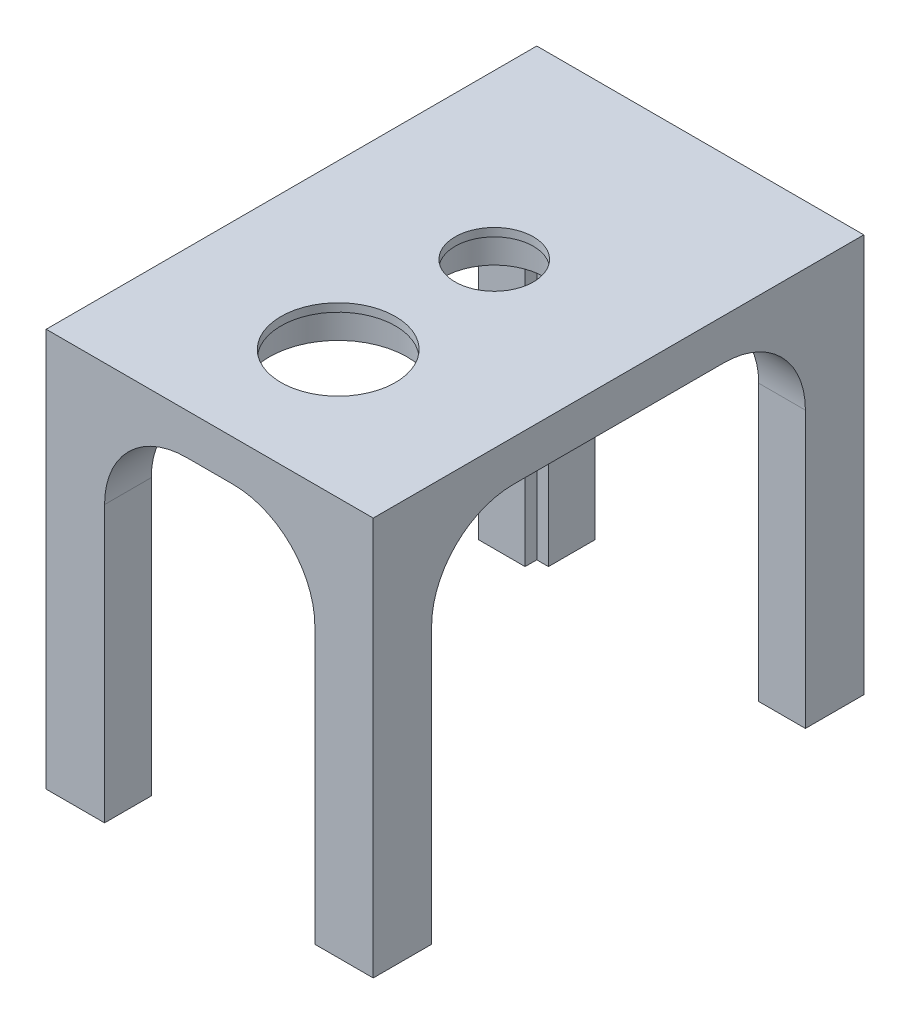
from build123d import *

# Parameters (mm, degrees)
SKETCH1_W               = 71.12
SKETCH1_H               = 106.68
BOSS_EXTRUDE1_DEPTH     = 87.884
SHELL1_T                = -10.16
SKETCH3_R               = 1.5875
CUT_EXTRUDE1_DEPTH      = 10.16
SKETCH4_W               = 81.28
SKETCH4_H               = 77.724
CUT_EXTRUDE2_DEPTH      = 72.12
CUT_EXTRUDE3_DEPTH      = 3.175
SKETCH7_W               = 45.72
SKETCH7_H               = 77.724
CUT_EXTRUDE4_DEPTH      = 1
CUT_EXTRUDE4_DEPTH_BACK = 107.68
SKETCH9_W               = 71.12
SKETCH9_H               = 106.68
CUT_EXTRUDE6_DEPTH      = 1.27
SKETCH10_R              = 14.986
SKETCH10_R_2            = 11.049
CUT_EXTRUDE7_DEPTH      = 7.112
SKETCH11_R              = 12.446
SKETCH11_R_2            = 8.509
CUT_EXTRUDE9_DEPTH      = 9.89
FILLET1_R               = 17.78


with BuildPart() as part:
    # Sketch1 → Boss-Extrude1 (new body)
    with BuildSketch(Plane(origin=(0, 0, 0), x_dir=(1, 0, 0), z_dir=(0, 1, 0))):
        with Locations((35.56, 53.34)):
            Rectangle(SKETCH1_W, SKETCH1_H)
    extrude(amount=BOSS_EXTRUDE1_DEPTH)

    # Shell1
    shell1_openings = [part.faces().sort_by_distance(p)[0] for p in [
        (35.56, 0, -53.34),
    ]]
    offset(amount=SHELL1_T, openings=shell1_openings, kind=Kind.INTERSECTION)

    # Sketch3 → Cut-Extrude1 (cut)
    with BuildSketch(Plane.XZ):
        with Locations((6.35, -6.35)):
            Circle(SKETCH3_R)
        with Locations((64.77, -6.35)):
            Circle(SKETCH3_R)
        with Locations((64.77, -100.33)):
            Circle(SKETCH3_R)
        with Locations((6.35, -100.33)):
            Circle(SKETCH3_R)
    extrude(amount=-CUT_EXTRUDE1_DEPTH, mode=Mode.SUBTRACT)

    # Sketch4 → Cut-Extrude2 (cut, through all)
    with BuildSketch(Plane.ZY):
        with Locations((-53.34, 38.862)):
            Rectangle(SKETCH4_W, SKETCH4_H)
    extrude(amount=-CUT_EXTRUDE2_DEPTH, mode=Mode.SUBTRACT)

    # Sketch6 → Cut-Extrude3 (cut)
    with BuildSketch(Plane.XZ):
        Polygon((69.536026472, -6.35), (67.153013236, -2.2225), (62.386986764, -2.2225), (60.003973528, -6.35), (62.386986764, -10.4775), (67.153013236, -10.4775), align=None)
        Polygon((11.116026472, -6.35), (8.733013236, -2.2225), (3.966986764, -2.2225), (1.583973528, -6.35), (3.966986764, -10.4775), (8.733013236, -10.4775), align=None)
        Polygon((69.536026472, -100.33), (67.153013236, -96.2025), (62.386986764, -96.2025), (60.003973528, -100.33), (62.386986764, -104.4575), (67.153013236, -104.4575), align=None)
        Polygon((11.116026472, -100.33), (8.733013236, -96.2025), (3.966986764, -96.2025), (1.583973528, -100.33), (3.966986764, -104.4575), (8.733013236, -104.4575), align=None)
    extrude(amount=-CUT_EXTRUDE3_DEPTH, mode=Mode.SUBTRACT)

    # Sketch7 → Cut-Extrude4 (cut, two sides)
    with BuildSketch(Plane(origin=(0, 0, -106.68), x_dir=(-1, 0, 0), z_dir=(0, 0, -1))) as cut_extrude4_sk:
        with Locations((-35.56, 38.862)):
            Rectangle(SKETCH7_W, SKETCH7_H)
    extrude(amount=CUT_EXTRUDE4_DEPTH, mode=Mode.SUBTRACT)
    extrude(cut_extrude4_sk.sketch, amount=-CUT_EXTRUDE4_DEPTH_BACK, mode=Mode.SUBTRACT)

    # Sketch9 → Cut-Extrude6 (cut)
    with BuildSketch(Plane(origin=(0, 87.884, 0), x_dir=(1, 0, 0), z_dir=(0, 1, 0))):
        with Locations((35.56, 53.34)):
            Rectangle(SKETCH9_W, SKETCH9_H)
    extrude(amount=-CUT_EXTRUDE6_DEPTH, mode=Mode.SUBTRACT)

    # Sketch10 → Cut-Extrude7 (cut)
    with BuildSketch(Plane(origin=(0, 77.724, 0), x_dir=(-1, 0, 0), z_dir=(0, -1, 0))):
        with Locations((-35.56, 27.94)):
            Circle(SKETCH10_R)
        with Locations((-35.56, 61.8744)):
            Circle(SKETCH10_R_2)
    extrude(amount=-CUT_EXTRUDE7_DEPTH, mode=Mode.SUBTRACT)

    # Sketch11 → Cut-Extrude9 (cut, through all)
    with BuildSketch(Plane.XZ.offset(-77.724)):
        with Locations((35.56, -27.94)):
            Circle(SKETCH11_R)
        with Locations((35.56, -61.8744)):
            Circle(SKETCH11_R_2)
    extrude(amount=-CUT_EXTRUDE9_DEPTH, mode=Mode.SUBTRACT)

    # Fillet1
    fillet1_edges = [part.edges().sort_by_distance(p)[0] for p in [
        (58.42, 77.724, -101.6),
        (58.42, 77.724, -5.08),
        (12.7, 77.724, -101.6),
        (12.7, 77.724, -5.08),
        (5.08, 77.724, -93.98),
        (5.08, 77.724, -12.7),
        (66.04, 77.724, -93.98),
        (66.04, 77.724, -12.7),
    ]]
    fillet(fillet1_edges, radius=FILLET1_R)


solid = part.part
